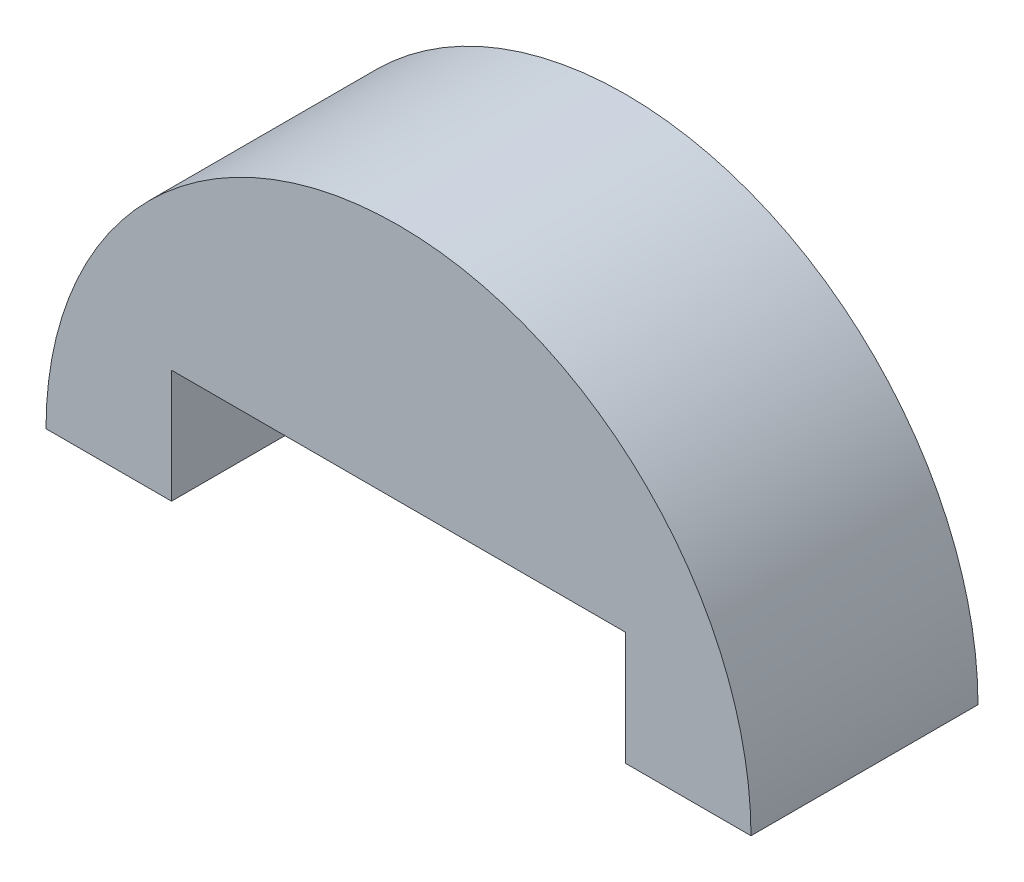
from build123d import *

# Parameters (mm, degrees)
BOSS_EXTRUDE1_DEPTH = 6


with BuildPart() as part:
    # Model → Boss-Extrude1 (new body)
    with BuildSketch(Plane.XY):
        with BuildLine():
            Line((3552.319202488, 1325.380918895), (3555.636280054, 1325.380918895))
            Line((3555.636280054, 1325.380918895), (3555.636280054, 1328.380918895))
            Line((3555.636280054, 1328.380918895), (3567.636280054, 1328.380918895))
            Line((3567.636280054, 1328.380918895), (3567.636280054, 1325.380918895))
            Line((3567.636280054, 1325.380918895), (3570.95335762, 1325.380918895))
            ThreePointArc((3570.95335762, 1325.380918895), (3561.636280054, 1334.697996461), (3552.319202488, 1325.380918895))
        make_face()
    extrude(amount=BOSS_EXTRUDE1_DEPTH)


solid = part.part
